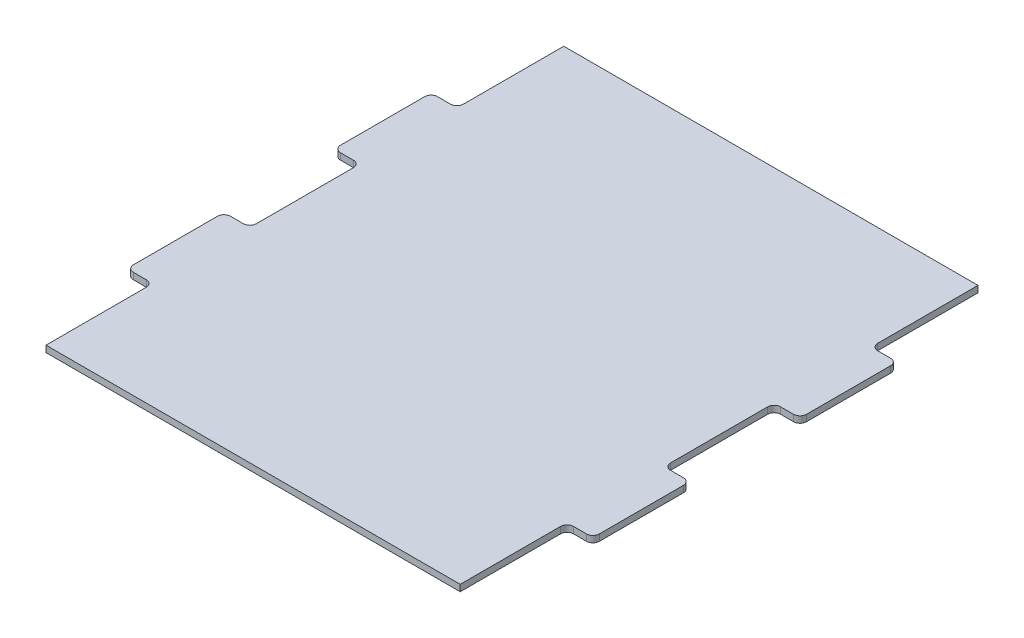
from build123d import *

# Parameters (mm, degrees)
SKETCH1_W           = 203.2
SKETCH1_H           = 254
BOSS_EXTRUDE1_DEPTH = 3.175
SKETCH2_W           = 228.6
SKETCH2_H           = 47.625
BOSS_EXTRUDE2_DEPTH = 3.175
FILLET1_R           = 3.175


with BuildPart() as part:
    # Sketch1 → Boss-Extrude1 (new body)
    with BuildSketch(Plane(origin=(0, 0, 0), x_dir=(1, 0, 0), z_dir=(0, 1, 0))):
        with Locations((101.6, -127)):
            Rectangle(SKETCH1_W, SKETCH1_H)
    extrude(amount=BOSS_EXTRUDE1_DEPTH)

    # Sketch2 → Boss-Extrude2 (add, through all)
    with BuildSketch(Plane(origin=(0, 3.175, 0), x_dir=(1, 0, 0), z_dir=(0, 1, 0))):
        with Locations((101.6, -76.2)):
            Rectangle(SKETCH2_W, SKETCH2_H)
        with Locations((101.6, -177.8)):
            Rectangle(SKETCH2_W, SKETCH2_H)
    extrude(amount=-BOSS_EXTRUDE2_DEPTH)

    # Fillet1
    fillet1_edges = [part.edges().sort_by_distance(p)[0] for p in [
        (215.9, 1.5875, 100.0125),
        (-12.7, 1.5875, 52.3875),
        (215.9, 1.5875, 52.3875),
        (0, 1.5875, 100.0125),
        (203.2, 1.5875, 100.0125),
        (-12.7, 1.5875, 100.0125),
        (0, 1.5875, 52.3875),
        (203.2, 1.5875, 52.3875),
        (215.9, 1.5875, 201.6125),
        (-12.7, 1.5875, 153.9875),
        (215.9, 1.5875, 153.9875),
        (0, 1.5875, 201.6125),
        (203.2, 1.5875, 201.6125),
        (-12.7, 1.5875, 201.6125),
        (0, 1.5875, 153.9875),
        (203.2, 1.5875, 153.9875),
    ]]
    fillet(fillet1_edges, radius=FILLET1_R)


solid = part.part
